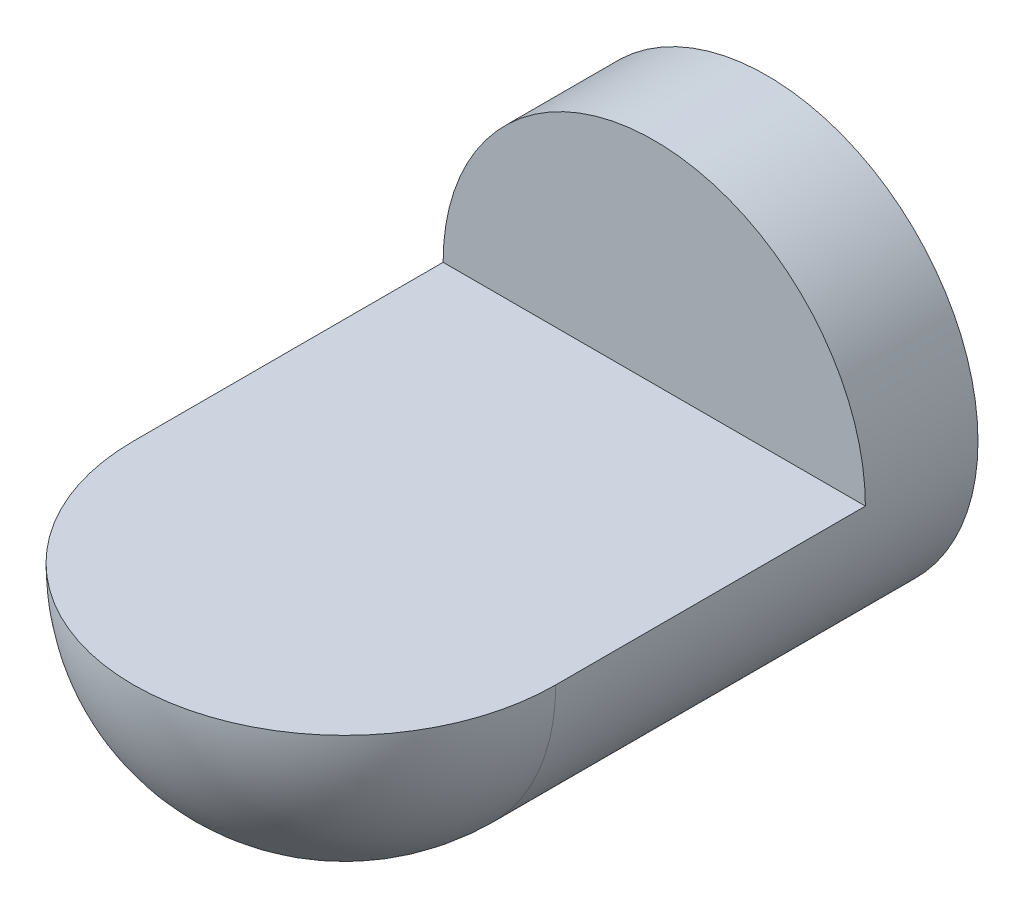
from build123d import *

# Parameters (mm, degrees)
CUT_EXTRUDE1_DEPTH      = 184.711730709
CUT_EXTRUDE1_DEPTH_BACK = 184.711730709


with BuildPart() as part:
    # Sketch1 → Revolve1 (revolve)
    with BuildSketch(Plane(origin=(0, 0, 0), x_dir=(0, 0, -1), z_dir=(1, 0, 0))):
        with BuildLine():
            Line((150, 0), (-75, 0))
            ThreePointArc((-75, 0), (-53.033008589, 53.033008589), (0, 75))
            Line((0, 75), (150, 75))
            Line((150, 75), (150, 0))
        make_face()
    revolve(axis=Axis((0, 0, 146.909145291), (0, 0, -1)))

    # Sketch2 → Cut-Extrude1 (cut, two sides: drawn at the far end of the back side and taken through both)
    with BuildSketch(Plane(origin=(0, 0, 0), x_dir=(0, 0, -1), z_dir=(1, 0, 0)).offset(-CUT_EXTRUDE1_DEPTH_BACK)):
        with BuildLine():
            Line((110, 0), (110, 75))
            Line((110, 75), (0, 75))
            ThreePointArc((0, 75), (-53.033008589, 53.033008589), (-75, 0))
            Line((-75, 0), (110, 0))
        make_face()
    extrude(amount=CUT_EXTRUDE1_DEPTH + CUT_EXTRUDE1_DEPTH_BACK, mode=Mode.SUBTRACT)


solid = part.part
